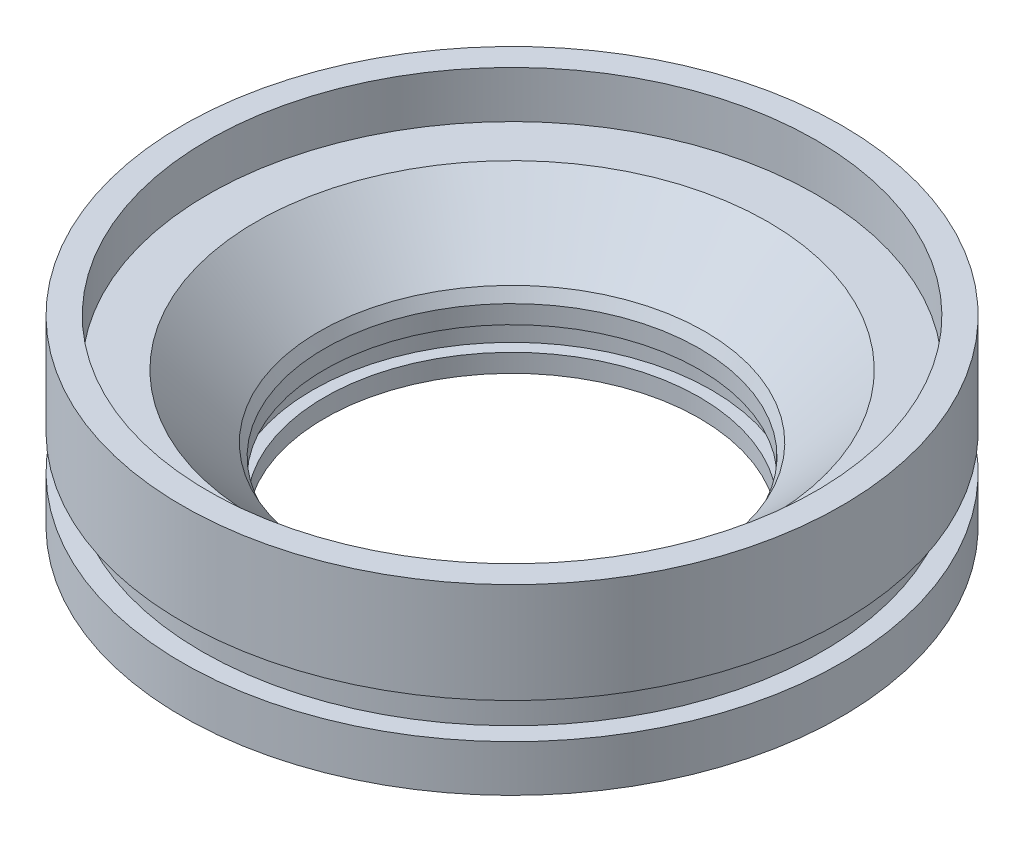
from build123d import *


with BuildPart() as part:
    # Sketch1 → Revolve1 (revolve)
    with BuildSketch(Plane.XY):
        Polygon((26.0731, 0), (26.0731, 2.54), (27.772310192, 2.54), (27.772310192, 5.8674), (26.0731, 5.8674), (26.0731, 8.4074), (26.8351, 10.06856), (35.63874, 18.8722), (42.29354, 18.8722), (42.29354, 25.4), (45.8597, 25.4), (45.8597, 11.43), (43.1419, 11.43), (43.1419, 6.477), (45.8597, 6.477), (45.8597, 0), align=None)
    revolve(axis=Axis((0, 0, 0), (0, 1, 0)))


solid = part.part
